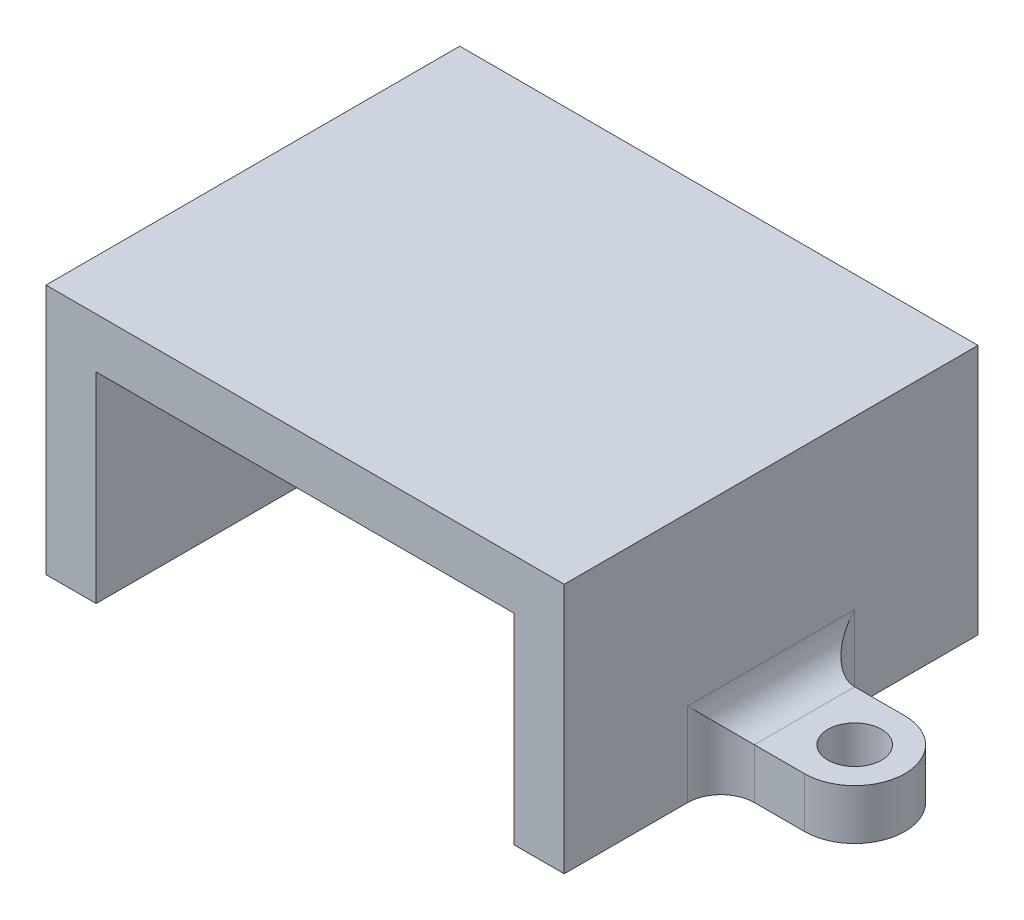
from build123d import *

# Parameters (mm, degrees)
EXTRUDE_1_DEPTH = 24.75
SKETCH_2_R      = 1.6
EXTRUDE_2_DEPTH = 3
FILLET_1_R      = 2
FILLET_2_R      = 2


with BuildPart() as part:
    # 草图1 → 凸台-拉伸1 (new body)
    with BuildSketch(Plane.XY):
        Polygon((0, 0), (3, 0), (3, 12), (28, 12), (28, 0), (31, 0), (31, 15), (0, 15), align=None)
    extrude(amount=EXTRUDE_1_DEPTH)

    # 草图2 → 凸台-拉伸2 (add)
    with BuildSketch(Plane.XZ):
        with BuildLine():
            Line((36, 9.375), (31, 9.375))
            Line((31, 9.375), (31, 15.375))
            Line((31, 15.375), (36, 15.375))
            ThreePointArc((36, 15.375), (39, 12.375), (36, 9.375))
        make_face()
        with Locations((36, 12.375)):
            Circle(SKETCH_2_R, mode=Mode.SUBTRACT)
        with BuildLine():
            Line((0, 15.375), (0, 9.375))
            Line((0, 9.375), (-5, 9.375))
            ThreePointArc((-5, 9.375), (-8, 12.375), (-5, 15.375))
            Line((-5, 15.375), (0, 15.375))
        make_face()
        with Locations((-5, 12.375)):
            Circle(SKETCH_2_R, mode=Mode.SUBTRACT)
    extrude(amount=-EXTRUDE_2_DEPTH)

    # 圆角1
    fillet_1_edges = [part.edges().sort_by_distance(p)[0] for p in [
        (31, 3, 12.375),
        (31, 1.5, 9.375),
        (31, 1.5, 15.375),
    ]]
    fillet(fillet_1_edges, radius=FILLET_1_R)

    # 圆角2
    fillet_2_edges = [part.edges().sort_by_distance(p)[0] for p in [
        (0, 3, 12.375),
        (0, 1.5, 15.375),
        (0, 1.5, 9.375),
    ]]
    fillet(fillet_2_edges, radius=FILLET_2_R)


solid = part.part
